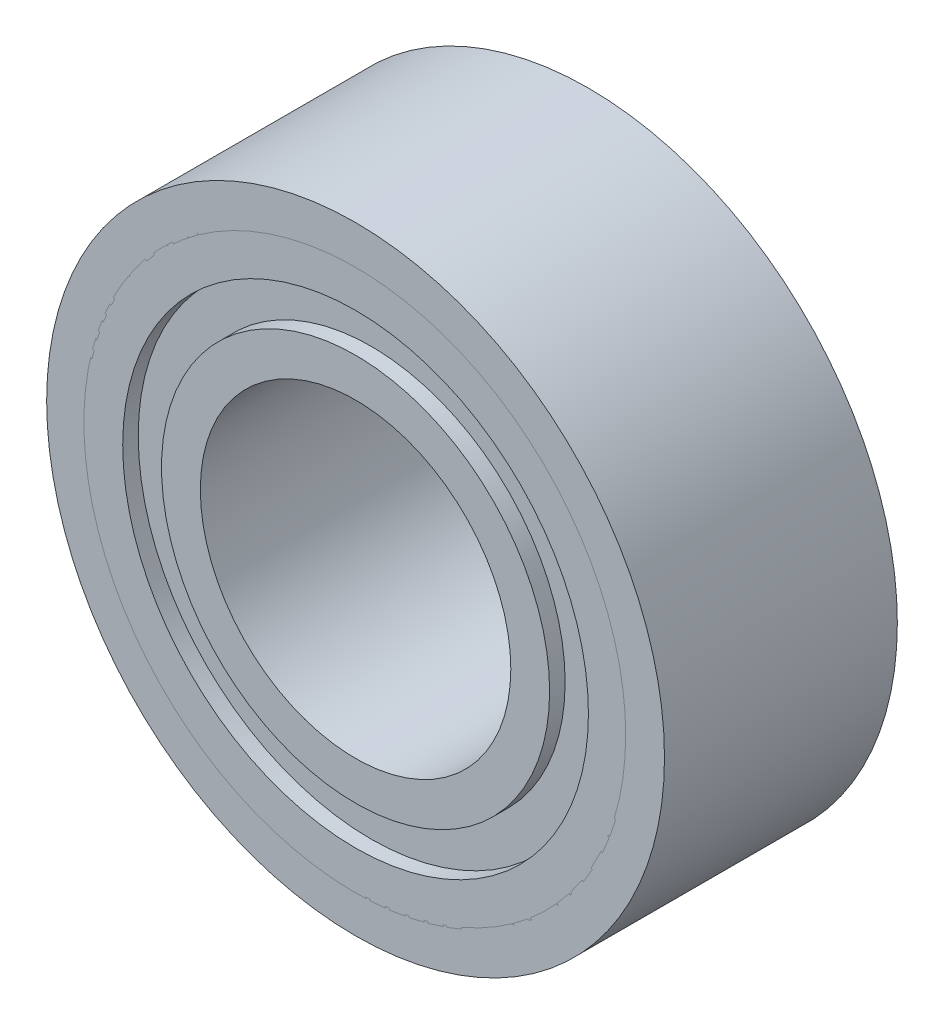
from build123d import *

# Parameters (mm, degrees)
SKETCH1_R           = 3.98
SKETCH1_R_2         = 2
BOSS_EXTRUDE1_DEPTH = 3
SKETCH2_R           = 3.48
SKETCH2_R_2         = 2.5
CUT_EXTRUDE1_DEPTH  = 3
SKETCH3_R           = 3.5
SKETCH3_R_2         = 2.5
BOSS_EXTRUDE3_DEPTH = 2.8
SKETCH4_R           = 3
SKETCH4_R_2         = 2
CUT_EXTRUDE2_DEPTH  = 0.2


with BuildPart() as part:
    # Sketch1 → Boss-Extrude1 (new body)
    with BuildSketch(Plane.XY):
        Circle(SKETCH1_R)
        Circle(SKETCH1_R_2, mode=Mode.SUBTRACT)
    extrude(amount=BOSS_EXTRUDE1_DEPTH)

    # Sketch2 → Cut-Extrude1 (cut)
    with BuildSketch(Plane.XY.offset(3)):
        Circle(SKETCH2_R)
        Circle(SKETCH2_R_2, mode=Mode.SUBTRACT)
    extrude(amount=-CUT_EXTRUDE1_DEPTH, mode=Mode.SUBTRACT)


with BuildPart() as body_2:
    # Sketch3 → Boss-Extrude3 (new body)
    with BuildSketch(Plane.XY.offset(3)):
        Circle(SKETCH3_R)
        Circle(SKETCH3_R_2, mode=Mode.SUBTRACT)
    extrude(amount=-BOSS_EXTRUDE3_DEPTH)

    # Sketch4 → Cut-Extrude2 (cut)
    with BuildSketch(Plane.XY.offset(3)):
        Circle(SKETCH4_R)
        Circle(SKETCH4_R_2, mode=Mode.SUBTRACT)
    extrude(amount=-CUT_EXTRUDE2_DEPTH, mode=Mode.SUBTRACT)


solid = Compound([part.part, body_2.part])
